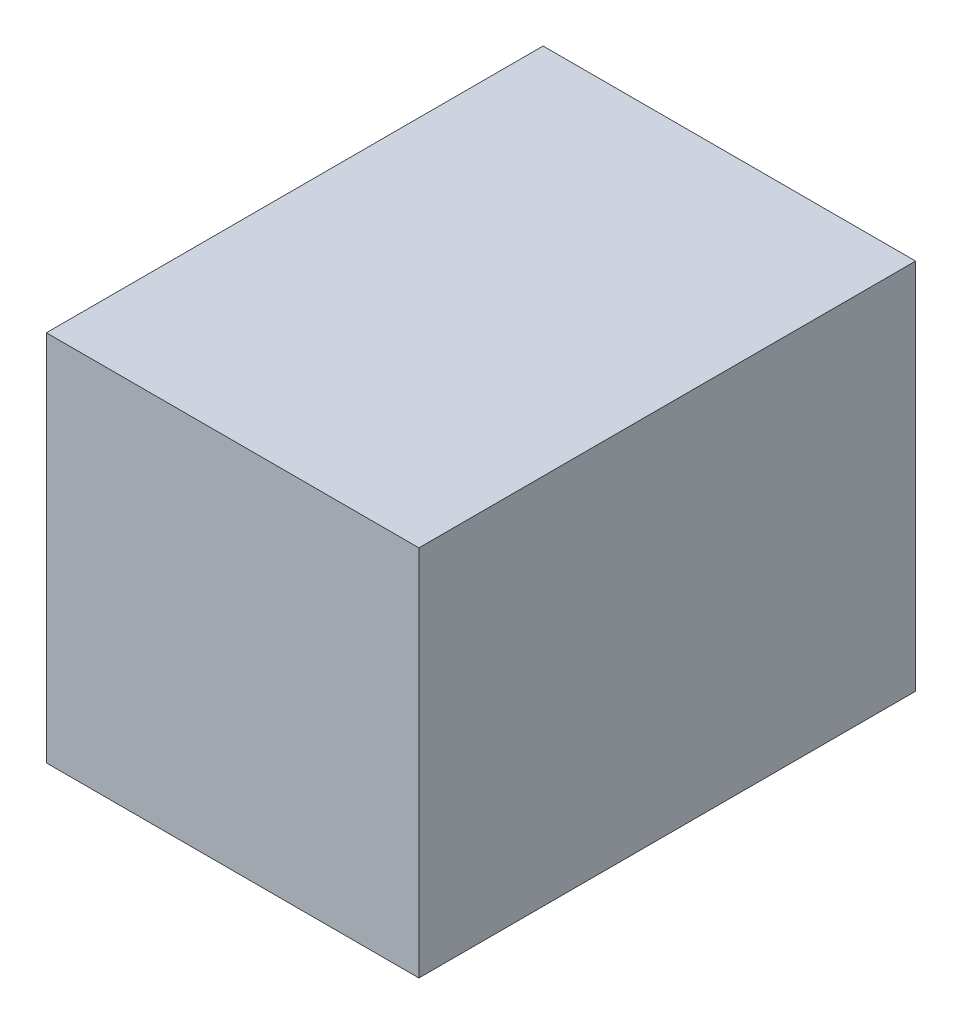
from build123d import *

# Parameters (mm, degrees)
SKETCH1_W           = 76.2
SKETCH1_H           = 76.2
BOSS_EXTRUDE1_DEPTH = 101.6


with BuildPart() as part:
    # Sketch1 → Boss-Extrude1 (new body)
    with BuildSketch(Plane.XY):
        with Locations((38.1, 38.1)):
            Rectangle(SKETCH1_W, SKETCH1_H)
    extrude(amount=BOSS_EXTRUDE1_DEPTH)


solid = part.part
